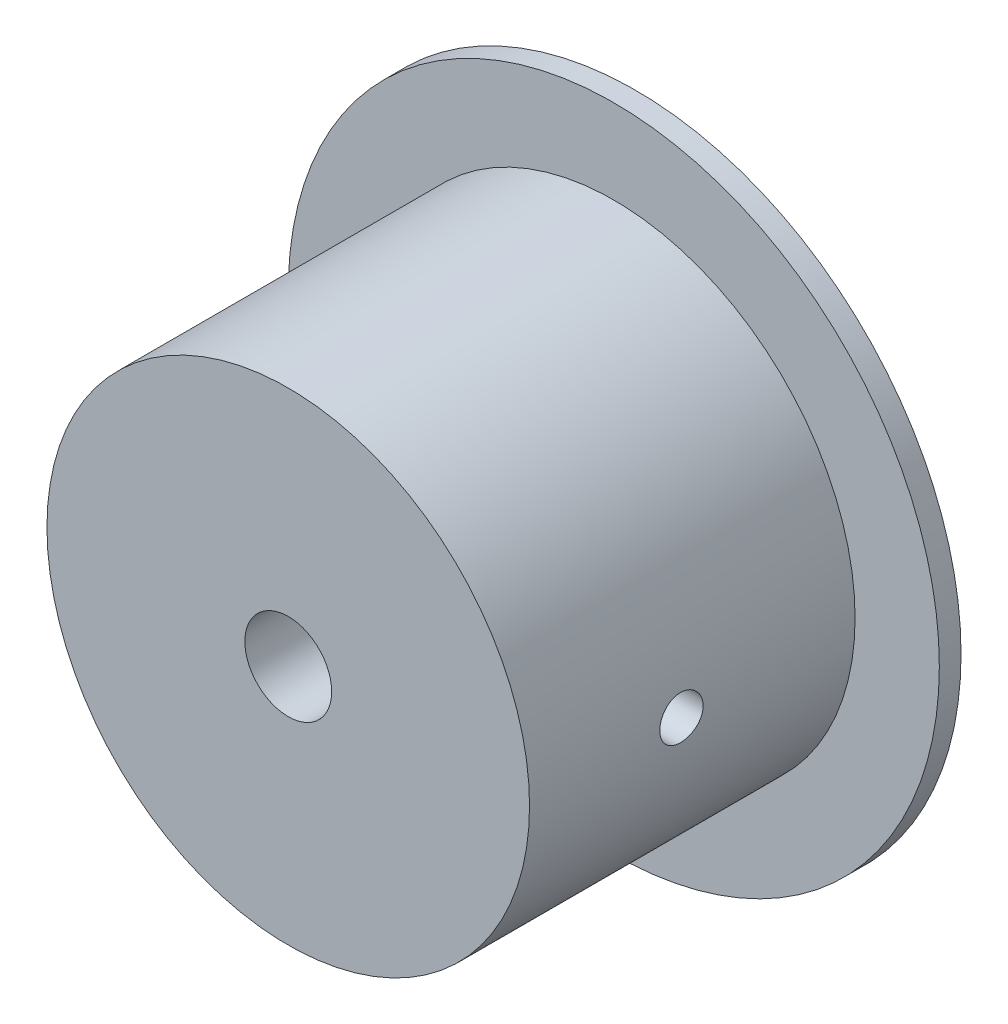
from build123d import *

# Parameters (mm, degrees)
IZIM1_R                     = 15
Y_KSEKLIK_EKSTR_ZYON1_DEPTH = 1
IZIM2_R                     = 11.118013459
Y_KSEKLIK_EKSTR_ZYON2_DEPTH = 15
IZIM3_R                     = 2
KES_EKSTR_ZYON1_DEPTH       = 17
SKETCH1_R                   = 1
CUT_EXTRUDE1_DEPTH          = 31.799728609


with BuildPart() as part:
    # Çizim1 → Yükseklik-Ekstrüzyon1 (new body)
    with BuildSketch(Plane.XY):
        with Locations((-15.799728609, 0)):
            Circle(IZIM1_R)
    extrude(amount=Y_KSEKLIK_EKSTR_ZYON1_DEPTH)

    # Çizim2 → Yükseklik-Ekstrüzyon2 (add)
    with BuildSketch(Plane.XY.offset(1)):
        with Locations((-15.799728609, 0)):
            Circle(IZIM2_R)
    extrude(amount=Y_KSEKLIK_EKSTR_ZYON2_DEPTH)

    # Çizim3 → Kes-Ekstrüzyon1 (cut, through all)
    with BuildSketch(Plane.XY.offset(16)):
        with Locations((-15.799728609, 0)):
            Circle(IZIM3_R)
    extrude(amount=-KES_EKSTR_ZYON1_DEPTH, mode=Mode.SUBTRACT)

    # Sketch1 → Cut-Extrude1 (cut, through all)
    with BuildSketch(Plane(origin=(0, 0, 0), x_dir=(0, 0, -1), z_dir=(1, 0, 0))):
        with Locations((-9, 0)):
            Circle(SKETCH1_R)
    extrude(amount=-CUT_EXTRUDE1_DEPTH, mode=Mode.SUBTRACT)


solid = part.part
